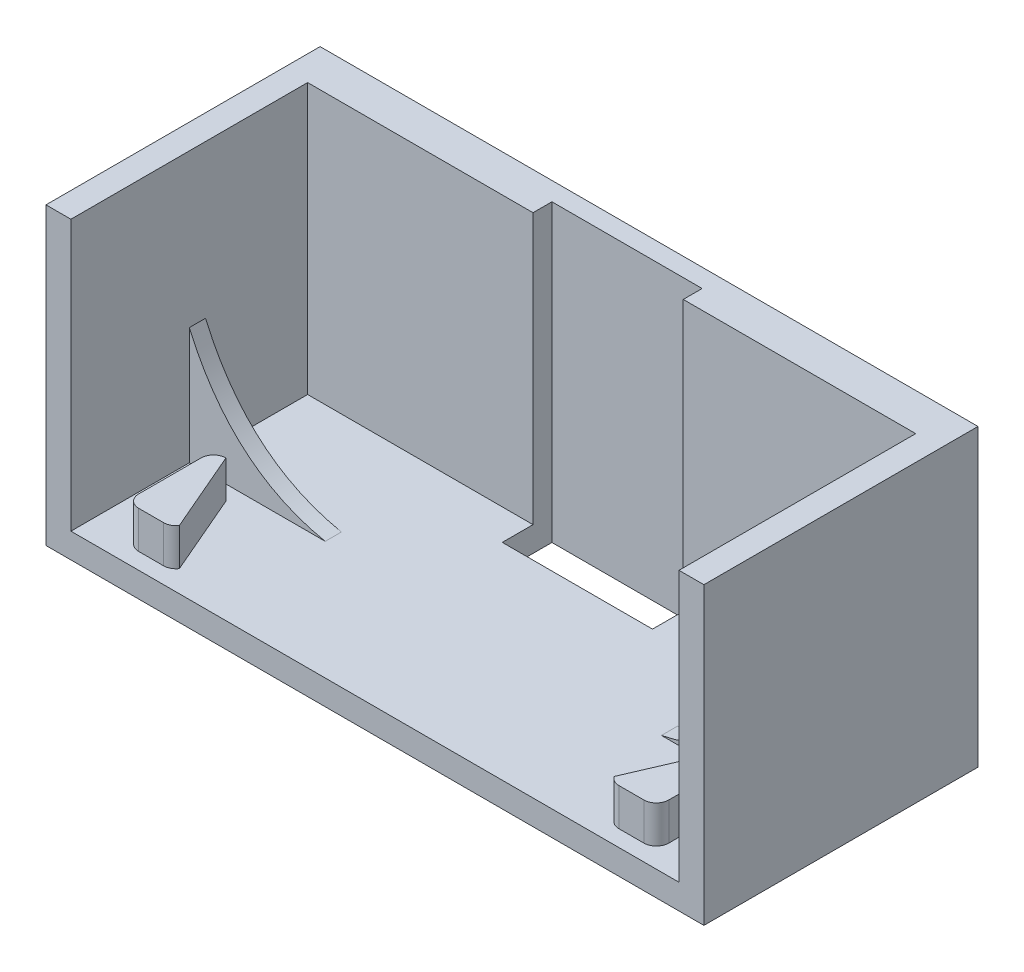
from build123d import *

# Parameters (mm, degrees)
SALIENTE_EXTRUIR1_DEPTH = 19
CROQUIS3_W              = 52.808095268
CROQUIS3_H              = 23.684781413
SALIENTE_EXTRUIR2_DEPTH = 3
CROQUIS4_W              = 12.057899081
CROQUIS4_H              = 3.984349261
CORTAR_EXTRUIR1_DEPTH   = 26
SALIENTE_EXTRUIR3_DEPTH = 3
SALIENTE_EXTRUIR4_DEPTH = 1.3


with BuildPart() as part:
    # Croquis1 → Saliente-Extruir1 (new body)
    with BuildSketch(Plane.XY):
        Polygon((-24.404047634, 20.4), (-24.404047634, -1.284781413), (24.404047634, -1.284781413), (24.404047634, 20.4), (26.404047634, 20.4), (26.404047634, -3.284781413), (-26.404047634, -3.284781413), (-26.404047634, 20.4), align=None)
    extrude(amount=-SALIENTE_EXTRUIR1_DEPTH)

    # Croquis3 → Saliente-Extruir2 (add)
    with BuildSketch(Plane(origin=(0, 0, -19), x_dir=(-1, 0, 0), z_dir=(0, 0, -1))):
        with Locations((0, 8.557609294)):
            Rectangle(CROQUIS3_W, CROQUIS3_H)
    extrude(amount=SALIENTE_EXTRUIR2_DEPTH)

    # Croquis4 → Cortar-Extruir1 (cut)
    with BuildSketch(Plane.XZ.offset(3.284781413)):
        with Locations((-0.283990929, -18.525322076)):
            Rectangle(CROQUIS4_W, CROQUIS4_H)
    extrude(amount=-CORTAR_EXTRUIR1_DEPTH, mode=Mode.SUBTRACT)

    # Croquis8 → Saliente-Extruir3 (add)
    with BuildSketch(Plane(origin=(0, -1.284781413, 0), x_dir=(1, 0, 0), z_dir=(0, 1, 0))):
        with BuildLine():
            Line((-20.273206473, 1.311556937), (-18.273206473, 1.311556937))
            ThreePointArc((-18.273206473, 1.311556937), (-17.806113325, 1.427348822), (-17.447191369, 1.747908954))
            Line((-17.447191369, 1.747908954), (-20.273206473, 8.311556937))
            ThreePointArc((-20.273206473, 8.311556937), (-20.980313254, 8.018663718), (-21.273206473, 7.311556937))
            Line((-21.273206473, 7.311556937), (-21.273206473, 2.311556937))
            ThreePointArc((-21.273206473, 2.311556937), (-20.980313254, 1.604450156), (-20.273206473, 1.311556937))
        make_face()
        with BuildLine():
            Line((20.273206473, 1.311556937), (18.273206473, 1.311556937))
            ThreePointArc((18.273206473, 1.311556937), (17.806113325, 1.427348822), (17.447191369, 1.747908954))
            Line((17.447191369, 1.747908954), (20.273206473, 8.311556937))
            ThreePointArc((20.273206473, 8.311556937), (20.980313254, 8.018663718), (21.273206473, 7.311556937))
            Line((21.273206473, 7.311556937), (21.273206473, 2.311556937))
            ThreePointArc((21.273206473, 2.311556937), (20.980313254, 1.604450156), (20.273206473, 1.311556937))
        make_face()
    extrude(amount=SALIENTE_EXTRUIR3_DEPTH)

    # Croquis9 → Saliente-Extruir4 (add)
    with BuildSketch(Plane(origin=(0, 0, -9.5), x_dir=(-1, 0, 0), z_dir=(0, 0, -1))):
        with BuildLine():
            Line((24.404047634, -1.284781413), (13.491213659, -1.284781413))
            add(Edge.make_bspline(
                [(24.404047634, 8.114982057), (20.954967317, 0.215218587), (13.491213659, -1.284781413)],
                knots=[0, 0, 0, 1, 1, 1], degree=2))
            Line((24.404047634, 8.114982057), (24.404047634, -1.284781413))
        make_face()
        with BuildLine():
            Line((-24.404047634, -1.284781413), (-13.491213659, -1.284781413))
            add(Edge.make_bspline(
                [(-24.404047634, 8.114982057), (-20.954967317, 0.215218587), (-13.491213659, -1.284781413)],
                knots=[0, 0, 0, 1, 1, 1], degree=2))
            Line((-24.404047634, 8.114982057), (-24.404047634, -1.284781413))
        make_face()
    extrude(amount=SALIENTE_EXTRUIR4_DEPTH)


solid = part.part
